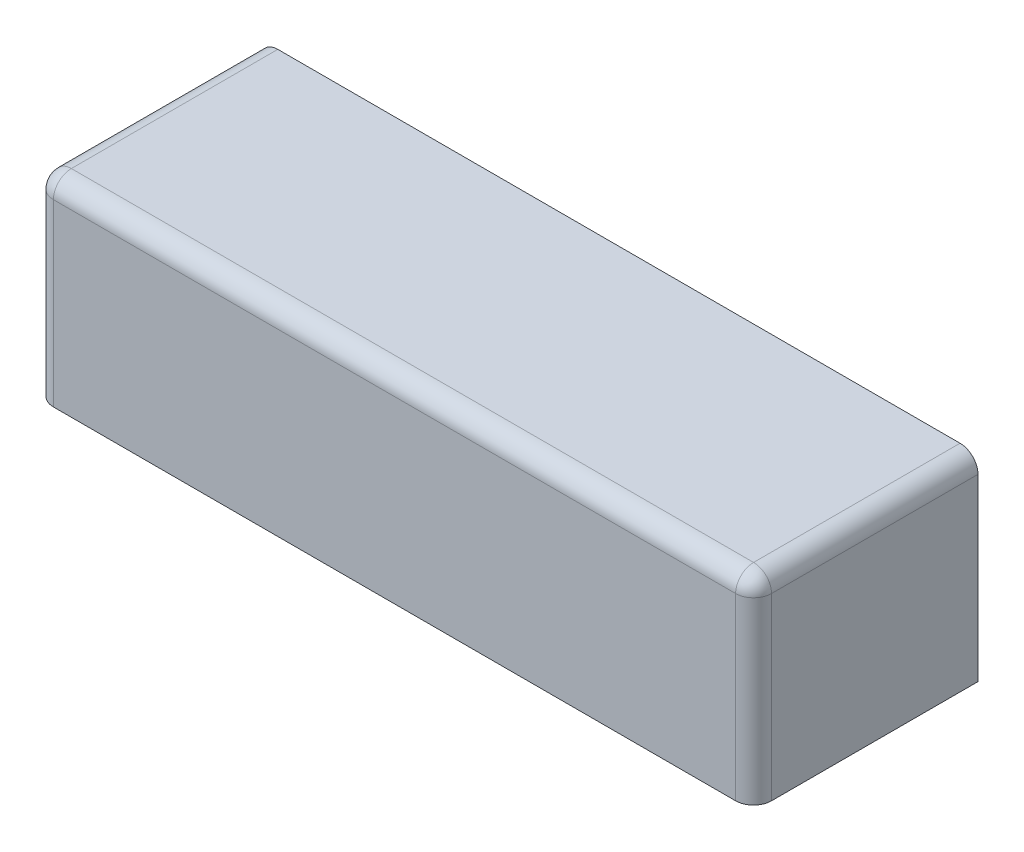
from build123d import *

# Parameters (mm, degrees)
SKETCH_1_W      = 400
SKETCH_1_H      = 110
EXTRUDE_1_DEPTH = 125
FILLET_1_R      = 10
SHELL_1_T       = -3


with BuildPart() as part:
    # 草图1 → 凸台-拉伸1 (new body)
    with BuildSketch(Plane.XY):
        Rectangle(SKETCH_1_W, SKETCH_1_H)
    extrude(amount=EXTRUDE_1_DEPTH)

    # 圆角1
    fillet_1_edges = [part.edges().sort_by_distance(p)[0] for p in [
        (-200, 0, 125),
        (200, 0, 125),
        (0, 55, 125),
        (-200, 55, 62.5),
        (200, 55, 62.5),
    ]]
    fillet(fillet_1_edges, radius=FILLET_1_R)

    # 抽壳1
    shell_1_openings = [part.faces().sort_by_distance(p)[0] for p in [
        (0, 15.690355937, 0),
        (0, -55, 80.690355937),
    ]]
    offset(amount=SHELL_1_T, openings=shell_1_openings, kind=Kind.INTERSECTION)


solid = part.part
